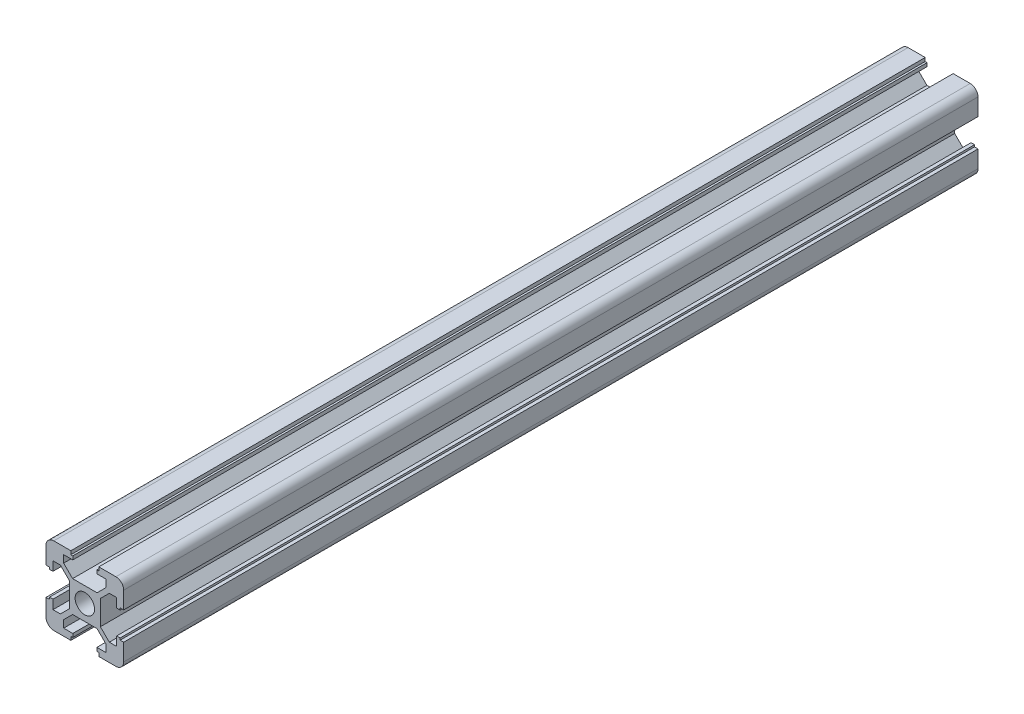
from build123d import *

# Parameters (mm, degrees)
SKETCH_1_R      = 2.5
EXTRUDE_1_DEPTH = 220
FILLET_1_R      = 2


with BuildPart() as part:
    # 草图1 → 凸台-拉伸1 (new body)
    with BuildSketch(Plane.XY):
        Polygon((-3.151471863, 4), (3.151471863, 4), (5.45, 6.298528137), (5.45, 8.2), (3.1, 8.2), (3.1, 9.1), (3.6, 9.1), (3.6, 10), (10, 10), (10, 3.6), (9.1, 3.6), (9.1, 3.1), (8.2, 3.1), (8.2, 5.45), (6.298528137, 5.45), (4, 3.151471863), (4, -3.151471863), (6.298528137, -5.45), (8.2, -5.45), (8.2, -3.1), (9.1, -3.1), (9.1, -3.6), (10, -3.6), (10, -10), (3.6, -10), (3.6, -9.1), (3.1, -9.1), (3.1, -8.2), (5.45, -8.2), (5.45, -6.298528137), (3.151471863, -4), (-3.151471863, -4), (-5.45, -6.298528137), (-5.45, -8.2), (-3.1, -8.2), (-3.1, -9.1), (-3.6, -9.1), (-3.6, -10), (-10, -10), (-10, -3.6), (-9.1, -3.6), (-9.1, -3.1), (-8.2, -3.1), (-8.2, -5.45), (-6.298528137, -5.45), (-4, -3.151471863), (-4, 3.151471863), (-6.298528137, 5.45), (-8.2, 5.45), (-8.2, 3.1), (-9.1, 3.1), (-9.1, 3.6), (-10, 3.6), (-10, 10), (-3.6, 10), (-3.6, 9.1), (-3.1, 9.1), (-3.1, 8.2), (-5.45, 8.2), (-5.45, 6.298528137), align=None)
        Circle(SKETCH_1_R, mode=Mode.SUBTRACT)
    extrude(amount=EXTRUDE_1_DEPTH)

    # 圆角1
    fillet_1_edges = [part.edges().sort_by_distance(p)[0] for p in [
        (10, -10, 110),
        (-10, -10, 110),
        (-10, 10, 110),
        (10, 10, 110),
    ]]
    fillet(fillet_1_edges, radius=FILLET_1_R)


solid = part.part
